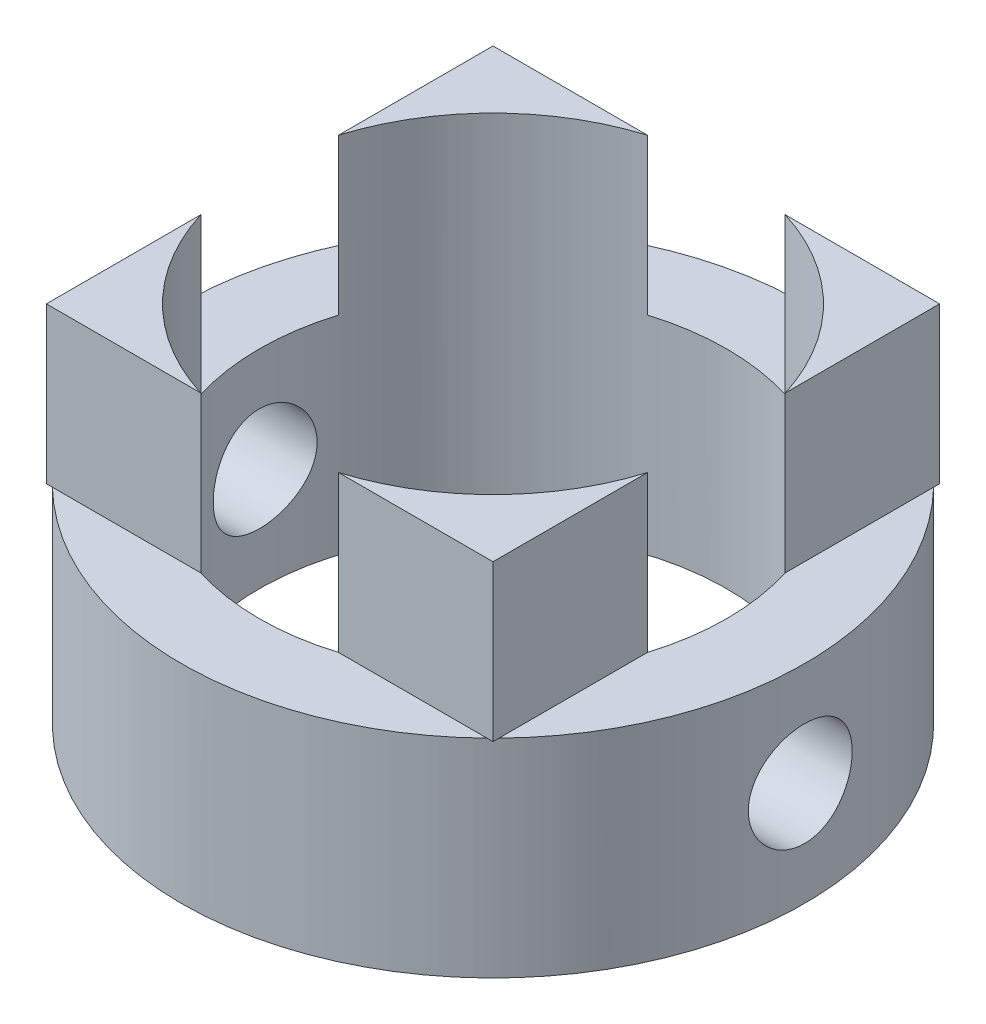
from build123d import *

# Parameters (mm, degrees)
SKETCH1_R               = 6
SKETCH1_R_2             = 4.5
BOSS_EXTRUDE5_DEPTH     = 4
BOSS_EXTRUDE6_DEPTH     = 3
SKETCH4_R               = 1
CUT_EXTRUDE1_DEPTH      = 7
CUT_EXTRUDE1_DEPTH_BACK = 7


with BuildPart() as part:
    # Sketch1 → Boss-Extrude5 (new body)
    with BuildSketch(Plane(origin=(0, 0, 0), x_dir=(1, 0, 0), z_dir=(0, 1, 0))):
        Circle(SKETCH1_R)
        Circle(SKETCH1_R_2, mode=Mode.SUBTRACT)
    extrude(amount=BOSS_EXTRUDE5_DEPTH)

    # Sketch3 → Boss-Extrude6 (add)
    with BuildSketch(Plane(origin=(0, 4, 0), x_dir=(1, 0, 0), z_dir=(0, 1, 0))):
        with BuildLine():
            Line((1.326649916, 4.3), (4.3, 4.3))
            Line((4.3, 4.3), (4.3, 1.326649916))
            ThreePointArc((4.3, 1.326649916), (3.181980515, 3.181980515), (1.326649916, 4.3))
        make_face()
        with BuildLine():
            Line((-4.3, -4.3), (-1.326649916, -4.3))
            ThreePointArc((-1.326649916, -4.3), (-3.181980515, -3.181980515), (-4.3, -1.326649916))
            Line((-4.3, -1.326649916), (-4.3, -4.3))
        make_face()
        with BuildLine():
            Line((-4.3, 4.3), (-1.326649916, 4.3))
            ThreePointArc((-1.326649916, 4.3), (-3.181980515, 3.181980515), (-4.3, 1.326649916))
            Line((-4.3, 1.326649916), (-4.3, 4.3))
        make_face()
        with BuildLine():
            Line((4.3, -4.3), (4.3, -1.326649916))
            ThreePointArc((4.3, -1.326649916), (3.181980515, -3.181980515), (1.326649916, -4.3))
            Line((1.326649916, -4.3), (4.3, -4.3))
        make_face()
    extrude(amount=BOSS_EXTRUDE6_DEPTH)

    # Sketch4 → Cut-Extrude1 (cut, two sides)
    with BuildSketch(Plane(origin=(0, 0, 0), x_dir=(0, 0, -1), z_dir=(1, 0, 0))) as cut_extrude1_sk:
        with Locations((0, 2)):
            Circle(SKETCH4_R)
    extrude(amount=CUT_EXTRUDE1_DEPTH, mode=Mode.SUBTRACT)
    extrude(cut_extrude1_sk.sketch, amount=-CUT_EXTRUDE1_DEPTH_BACK, mode=Mode.SUBTRACT)


solid = part.part
